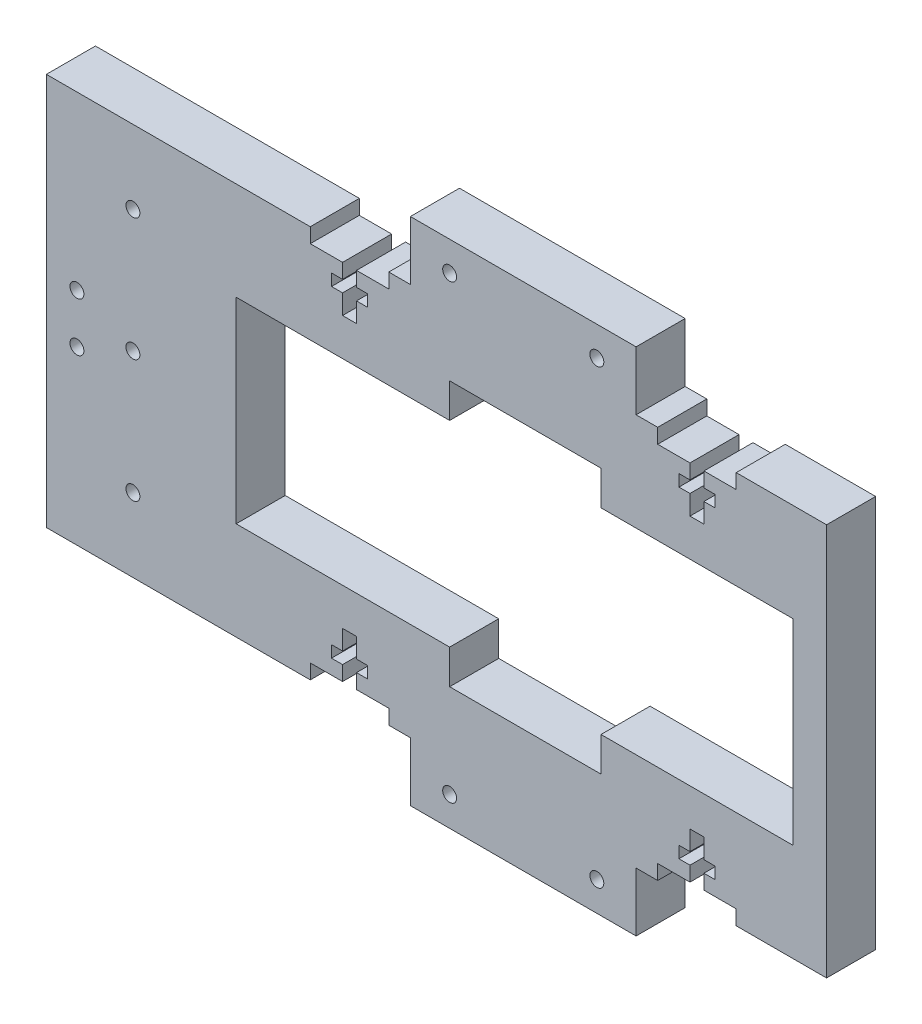
from build123d import *

# Parameters (mm, degrees)
SKETCH1_R           = 1.42
BOSS_EXTRUDE1_DEPTH = 10


with BuildPart() as part:
    # Sketch1 → Boss-Extrude1 (new body)
    with BuildSketch(Plane.XY):
        Polygon((109, 80), (109, 77), (115.58, 77), (115.58, 74), (113.33, 74), (113.33, 71.61), (115.58, 71.61), (115.58, 67.61), (118.42, 67.61), (118.42, 71.61), (120.67, 71.61), (120.67, 74), (118.42, 74), (118.42, 77), (125, 77), (125, 80), (143.417515172, 80), (143.417515172, 60), (143.417515172, 20), (143.417515172, 0), (125, 0), (125, 3), (118.42, 3), (118.42, 6), (120.67, 6), (120.67, 8.39), (118.42, 8.39), (118.42, 12.39), (115.58, 12.39), (115.58, 8.39), (113.33, 8.39), (113.33, 6), (115.58, 6), (115.58, 3), (109, 3), (109, 0), (104.593570259, 0), (104.593570259, -12), (58.593570259, -12), (58.593570259, 0), (54.187140517, 0), (54.187140517, 3), (47.607140517, 3), (47.607140517, 6), (49.857140517, 6), (49.857140517, 8.39), (47.607140517, 8.39), (47.607140517, 12.39), (44.767140517, 12.39), (44.767140517, 8.39), (42.517140517, 8.39), (42.517140517, 6), (44.767140517, 6), (44.767140517, 3), (38.187140517, 3), (38.187140517, 0), (0, 0), (-15.602079829, 0), (-15.602079829, 80), (5, 80), (38.187140517, 80), (38.187140517, 77), (44.767140517, 77), (44.767140517, 74), (42.517140517, 74), (42.517140517, 71.61), (44.767140517, 71.61), (44.767140517, 67.61), (47.607140517, 67.61), (47.607140517, 71.61), (49.857140517, 71.61), (49.857140517, 74), (47.607140517, 74), (47.607140517, 77), (54.187140517, 77), (54.187140517, 80), (58.593570259, 80), (58.593570259, 92), (104.593570259, 92), (104.593570259, 80), align=None)
        with Locations((2.037759908, 40)):
            Circle(SKETCH1_R, mode=Mode.SUBTRACT)
        with Locations((2.037759908, 65)):
            Circle(SKETCH1_R, mode=Mode.SUBTRACT)
        with Locations((2.037759908, 15)):
            Circle(SKETCH1_R, mode=Mode.SUBTRACT)
        with Locations((66.593570259, 86)):
            Circle(SKETCH1_R, mode=Mode.SUBTRACT)
        with Locations((96.593570259, 86)):
            Circle(SKETCH1_R, mode=Mode.SUBTRACT)
        with Locations((96.593570259, -6)):
            Circle(SKETCH1_R, mode=Mode.SUBTRACT)
        with Locations((66.593570259, -6)):
            Circle(SKETCH1_R, mode=Mode.SUBTRACT)
        with Locations((-9.374764666, 45)):
            Circle(SKETCH1_R, mode=Mode.SUBTRACT)
        with Locations((-9.374764666, 35)):
            Circle(SKETCH1_R, mode=Mode.SUBTRACT)
        Polygon((136.600558962, 60), (136.600558962, 20), (97.442765105, 20), (97.442765105, 13), (66.593570259, 13), (66.593570259, 20), (23.079003763, 20), (23.079003763, 60), (66.593570259, 60), (66.593570259, 67), (97.442765105, 67), (97.442765105, 60), align=None, mode=Mode.SUBTRACT)
    extrude(amount=BOSS_EXTRUDE1_DEPTH)


solid = part.part
